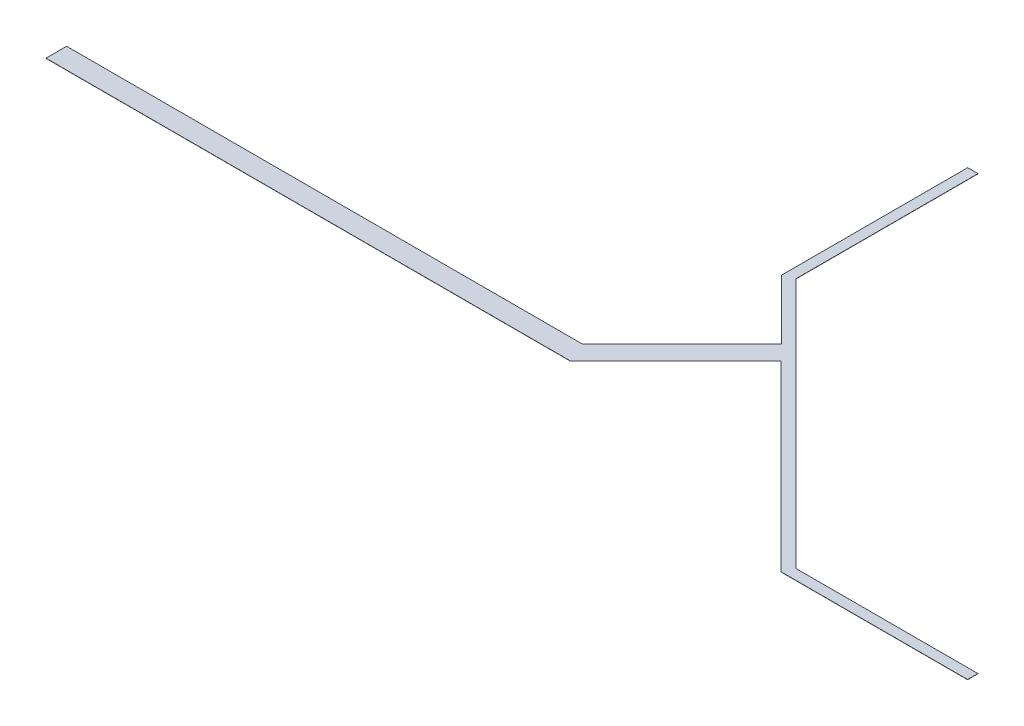
from build123d import *

# Parameters (mm, degrees)
BOSS_EXTRUDE1_DEPTH = 0.02
SCALE2_SCALE        = 0.5


with BuildPart() as part:
    # Sketch1 → Boss-Extrude1 (new body)
    with BuildSketch(Plane(origin=(0, 0, 0), x_dir=(1, 0, 0), z_dir=(0, 1, 0))):
        Polygon((0, 0), (0, 2), (50, 2), (59.652007563, 11.652007563), (53.889087297, 17.41492783), (53.889087297, 35.49492783), (54.889087297, 35.49492783), (54.889087297, 17.83492783), (79.209002128, -6.495331881), (96.869002128, -6.495331881), (96.869002128, -7.495331881), (78.789002128, -7.495331881), (61.061835124, 10.231835124), (50.83, 0), align=None)
    extrude(amount=BOSS_EXTRUDE1_DEPTH)


with BuildPart() as part_1:
    # Scale2: scaled about (44.956647526, 0.01, -4.024879093)
    add(part.part.scale(SCALE2_SCALE).moved(Location((22.478323763, 0.005, -2.012439547))))


solid = part_1.part
